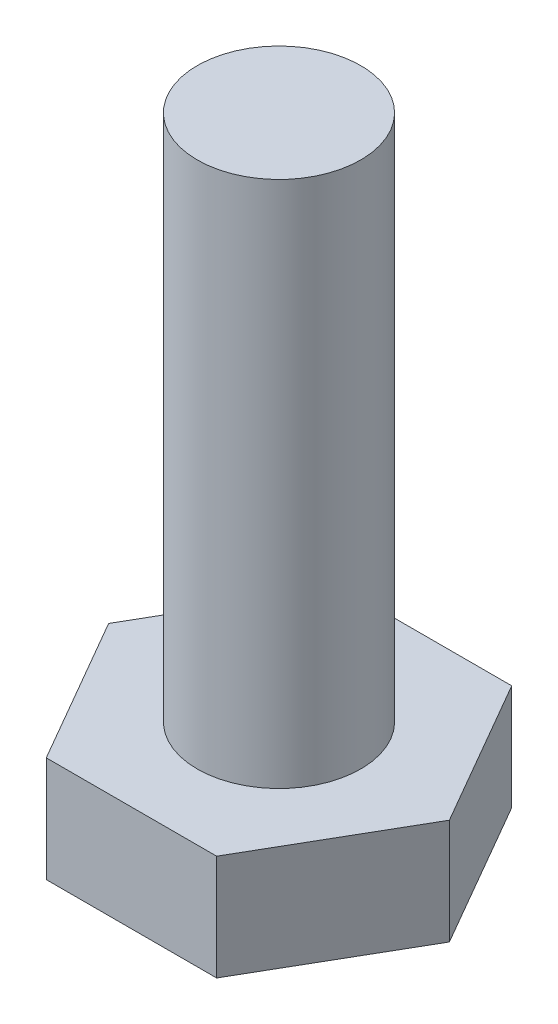
from build123d import *

# Parameters (mm, degrees)
EXTRUDE_1_DEPTH = 2
SKETCH_2_R      = 1.55
EXTRUDE_2_DEPTH = 10


with BuildPart() as part:
    # 스케치1 → 보스-돌출1 (new body)
    with BuildSketch(Plane(origin=(0, 0, 0), x_dir=(1, 0, 0), z_dir=(0, 1, 0))):
        Polygon((3.23, 0), (1.615, 2.797262054), (-1.615, 2.797262054), (-3.23, 0), (-1.615, -2.797262054), (1.615, -2.797262054), align=None)
    extrude(amount=EXTRUDE_1_DEPTH)

    # 스케치2 → 보스-돌출2 (add)
    with BuildSketch(Plane(origin=(0, 2, 0), x_dir=(1, 0, 0), z_dir=(0, 1, 0))):
        Circle(SKETCH_2_R)
    extrude(amount=EXTRUDE_2_DEPTH)


solid = part.part
